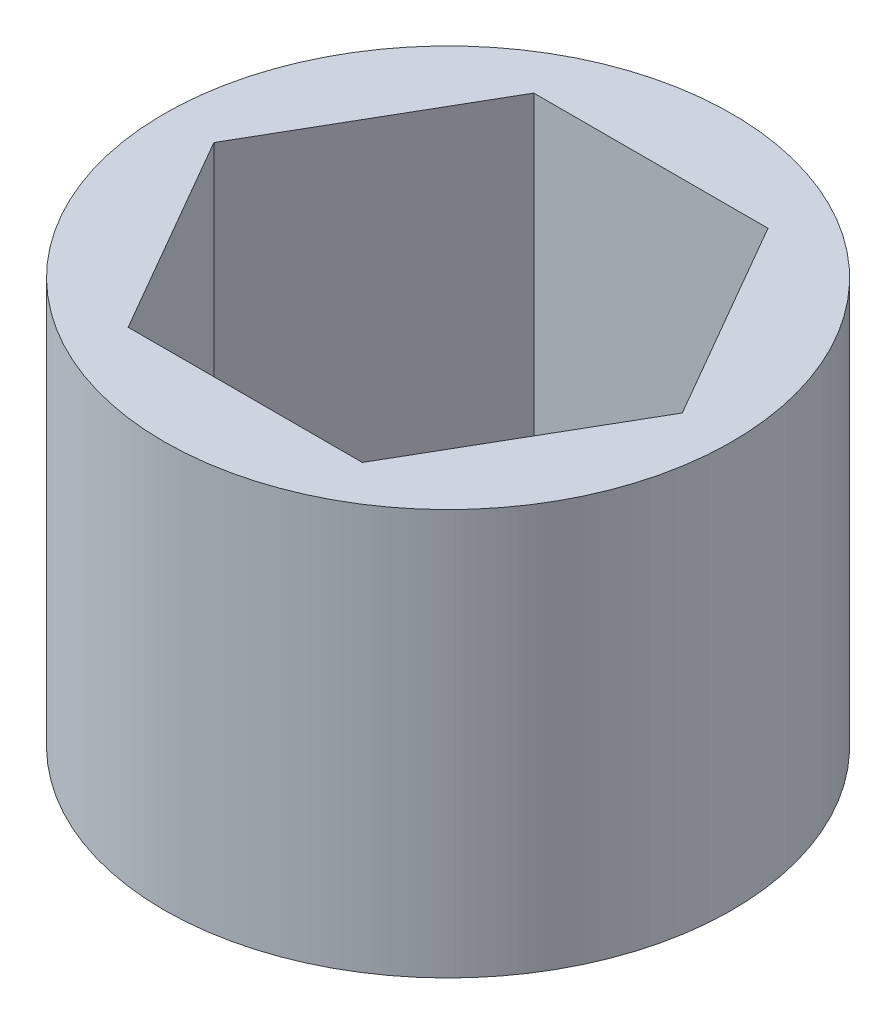
from build123d import *

# Parameters (mm, degrees)
SKETCH1_R           = 8.89
BOSS_EXTRUDE1_DEPTH = 12.7


with BuildPart() as part:
    # Sketch1 → Boss-Extrude1 (new body)
    with BuildSketch(Plane(origin=(0, 0, 0), x_dir=(1, 0, 0), z_dir=(0, 1, 0))):
        Circle(SKETCH1_R)
        Polygon((7.332348419, 0), (3.666174209, 6.35), (-3.666174209, 6.35), (-7.332348419, 0), (-3.666174209, -6.35), (3.666174209, -6.35), align=None, mode=Mode.SUBTRACT)
    extrude(amount=BOSS_EXTRUDE1_DEPTH)


solid = part.part
